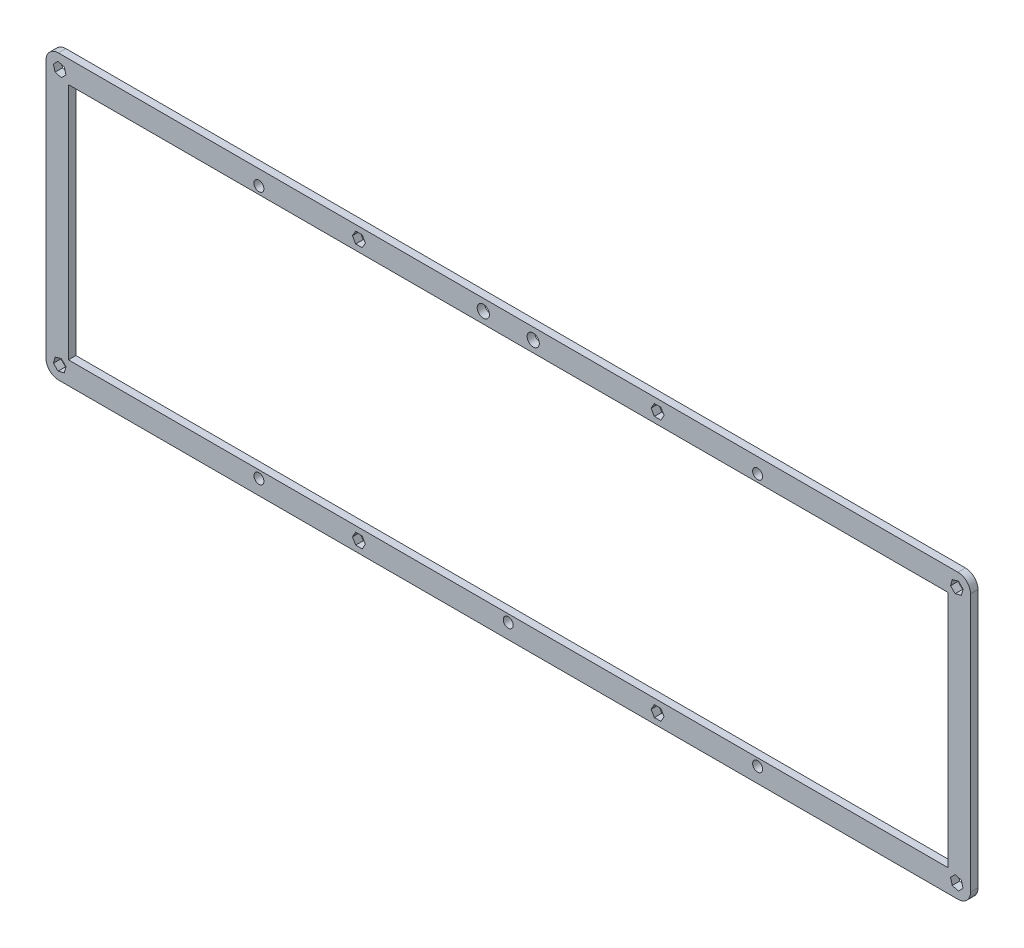
from build123d import *

# Parameters (mm, degrees)
MODEL_R             = 2
MODEL_R_2           = 2.45
MODEL_W             = 352.775
MODEL_H             = 95.6
BOSS_EXTRUDE1_DEPTH = 3


with BuildPart() as part:
    # Model → Boss-Extrude1 (new body)
    with BuildSketch(Plane.XY):
        with BuildLine():
            Line((0, 108.6), (0, 5))
            ThreePointArc((0, 5), (1.464466094, 1.464466094), (5, 0))
            Line((5, 0), (365.775, 0))
            ThreePointArc((365.775, 0), (369.310533906, 1.464466094), (370.775, 5))
            Line((370.775, 5), (370.775, 108.6))
            ThreePointArc((370.775, 108.6), (369.310533906, 112.135533906), (365.775, 113.6))
            Line((365.775, 113.6), (5, 113.6))
            ThreePointArc((5, 113.6), (1.464466094, 112.135533906), (0, 108.6))
        make_face()
        with Locations((85.3875, 107.6)):
            Circle(MODEL_R, mode=Mode.SUBTRACT)
        with Locations((285.3875, 107.6)):
            Circle(MODEL_R, mode=Mode.SUBTRACT)
        with Locations((85.3875, 6)):
            Circle(MODEL_R, mode=Mode.SUBTRACT)
        with Locations((185.3875, 6)):
            Circle(MODEL_R, mode=Mode.SUBTRACT)
        with Locations((285.3875, 6)):
            Circle(MODEL_R, mode=Mode.SUBTRACT)
        with Locations((175.3875, 109.1)):
            Circle(MODEL_R_2, mode=Mode.SUBTRACT)
        with Locations((195.3875, 109.1)):
            Circle(MODEL_R_2, mode=Mode.SUBTRACT)
        with Locations((185.3875, 56.8)):
            Rectangle(MODEL_W, MODEL_H, mode=Mode.SUBTRACT)
        Polygon((365.947431604, 110.609548911), (367.784548911, 108.772431604), (367.112117307, 106.262882693), (364.602568396, 105.590451089), (362.765451089, 107.427568396), (363.437882693, 109.937117307), align=None, mode=Mode.SUBTRACT)
        Polygon((4.827568396, 110.609548911), (2.990451089, 108.772431604), (3.662882693, 106.262882693), (6.172431604, 105.590451089), (8.009548911, 107.427568396), (7.337117307, 109.937117307), align=None, mode=Mode.SUBTRACT)
        Polygon((365.947431604, 2.990451089), (367.784548911, 4.827568396), (367.112117307, 7.337117307), (364.602568396, 8.009548911), (362.765451089, 6.172431604), (363.437882693, 3.662882693), align=None, mode=Mode.SUBTRACT)
        Polygon((4.827568396, 2.990451089), (2.990451089, 4.827568396), (3.662882693, 7.337117307), (6.172431604, 8.009548911), (8.009548911, 6.172431604), (7.337117307, 3.662882693), align=None, mode=Mode.SUBTRACT)
        Polygon((126.799038106, 2.25), (124.200961894, 2.25), (122.901923789, 4.5), (124.200961894, 6.75), (126.799038106, 6.75), (128.098076211, 4.5), align=None, mode=Mode.SUBTRACT)
        Polygon((126.799038106, 111.35), (124.200961894, 111.35), (122.901923789, 109.1), (124.200961894, 106.85), (126.799038106, 106.85), (128.098076211, 109.1), align=None, mode=Mode.SUBTRACT)
        Polygon((243.975961894, 2.25), (246.574038106, 2.25), (247.873076211, 4.5), (246.574038106, 6.75), (243.975961894, 6.75), (242.676923789, 4.5), align=None, mode=Mode.SUBTRACT)
        Polygon((243.975961894, 111.35), (246.574038106, 111.35), (247.873076211, 109.1), (246.574038106, 106.85), (243.975961894, 106.85), (242.676923789, 109.1), align=None, mode=Mode.SUBTRACT)
    extrude(amount=BOSS_EXTRUDE1_DEPTH)


solid = part.part
